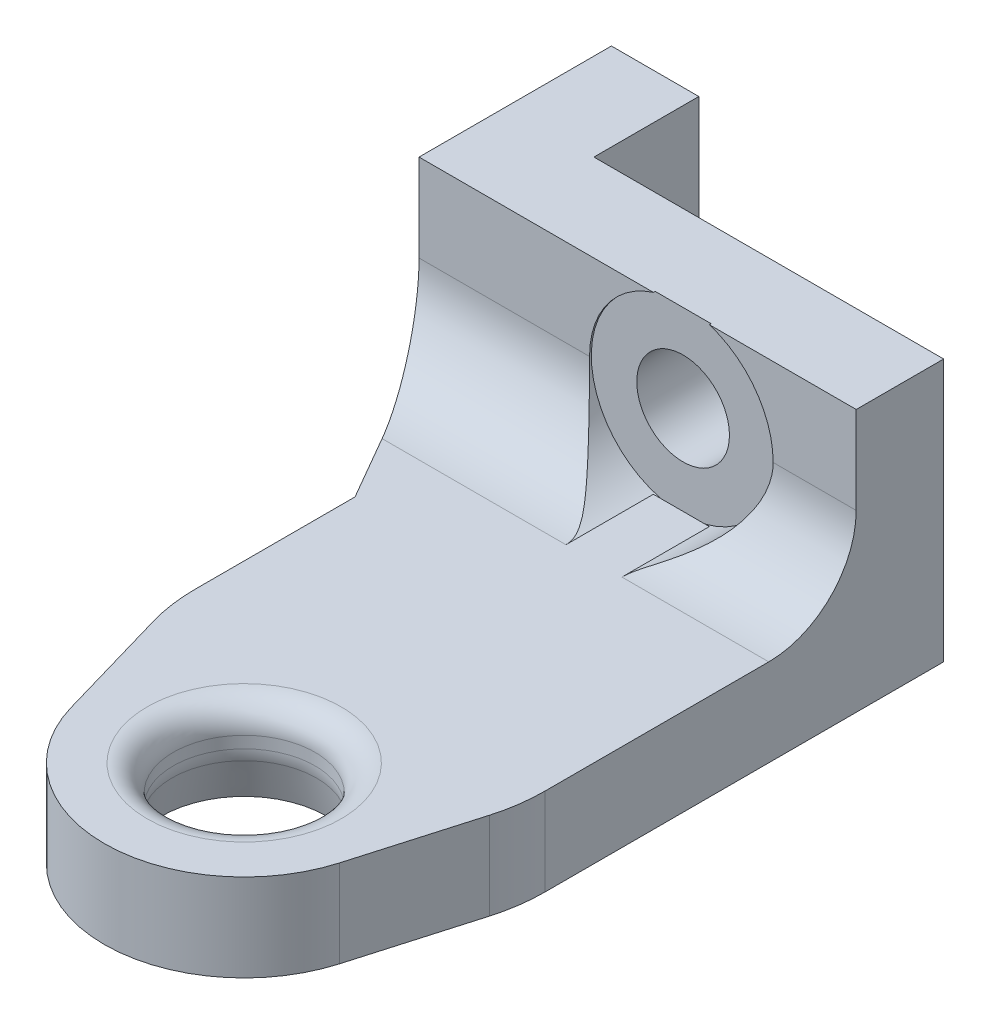
from build123d import *

# Parameters (mm, degrees)
BOSS_EXTRUDE1_DEPTH = 5
SKETCH2_W           = 25
SKETCH2_H           = 11
BOSS_EXTRUDE2_DEPTH = 10
SKETCH3_W           = 20
SKETCH3_H           = 6
CUT_EXTRUDE1_DEPTH  = 16
FILLET1_R           = 1.5
FILLET2_R           = 2.5
FILLET3_R           = 5
FILLET4_R           = 10


with BuildPart() as part:
    # Sketch1 → Boss-Extrude1 (new body)
    with BuildSketch(Plane(origin=(0, 5, 0), x_dir=(1, 0, 0), z_dir=(0, 1, 0))):
        with BuildLine():
            Line((10, 5.775897312), (10, 36))
            Line((10, 36), (-15, 36))
            Line((-15, 36), (-15, 25))
            Line((-15, 25), (-10, 16.339745962))
            Line((-10, 16.339745962), (-10, 5.775897312))
            Line((-10, 5.775897312), (-7.684618874, -2.224102688))
            ThreePointArc((-7.684618874, -2.224102688), (0, -8), (7.684618874, -2.224102688))
            Line((7.684618874, -2.224102688), (10, 5.775897312))
        make_face()
    extrude(amount=-BOSS_EXTRUDE1_DEPTH)

    # Sketch2 → Boss-Extrude2 (add)
    with BuildSketch(Plane(origin=(0, 5, 0), x_dir=(-1, 0, 0), z_dir=(0, 1, 0))):
        with Locations((2.5, -30.5)):
            Rectangle(SKETCH2_W, SKETCH2_H)
    extrude(amount=BOSS_EXTRUDE2_DEPTH)

    # Sketch3 → Cut-Extrude1 (cut, through all)
    with BuildSketch(Plane.XZ):
        with Locations((0, -33)):
            Rectangle(SKETCH3_W, SKETCH3_H)
    extrude(amount=-CUT_EXTRUDE1_DEPTH, mode=Mode.SUBTRACT)

    # Sketch6 → Ø8.1 (8.1) Diameter Hole1 (revolve, cut)
    with BuildSketch(Plane(origin=(0, 0, 0), x_dir=(0, 0, -1), z_dir=(1, 0, 0))):
        Polygon((0, 0), (0, 15), (4.05, 15), (4.05, 2.5), (4.719872981, 0), align=None)
    revolve(axis=Axis((0, -6.35, 0), (0, 1, 0)), mode=Mode.SUBTRACT)

    # Sketch4 → CBORE for M5 SBHCS1 (revolve, cut)
    with BuildSketch(Plane(origin=(0, 10, -25), x_dir=(0, -1, 0), z_dir=(1, 0, 0))):
        Polygon((0, 0), (0, 11), (2.65, 11), (2.65, 0.1), (5.25, 0.1), (5.25, 0), align=None)
    revolve(axis=Axis((0, 10, -18.65), (0, 0, -1)), mode=Mode.SUBTRACT)

    # Fillet1
    fillet1_edges = [part.edges().sort_by_distance(p)[0] for p in [
        (0, 5, 4.05),
    ]]
    fillet(fillet1_edges, radius=FILLET1_R)

    # Fillet2
    fillet2_edges = [part.edges().sort_by_distance(p)[0] for p in [
        (0, 2.5, 4.05),
    ]]
    fillet(fillet2_edges, radius=FILLET2_R)

    # Fillet3
    fillet3_edges = [part.edges().sort_by_distance(p)[0] for p in [
        (-8.30039053, 5, -25),
        (5.80039053, 5, -25),
    ]]
    fillet(fillet3_edges, radius=FILLET3_R)

    # Fillet4
    fillet4_edges = [part.edges().sort_by_distance(p)[0] for p in [
        (-10, 2.5, -5.775897312),
        (10, 2.5, -5.775897312),
    ]]
    fillet(fillet4_edges, radius=FILLET4_R)


solid = part.part
